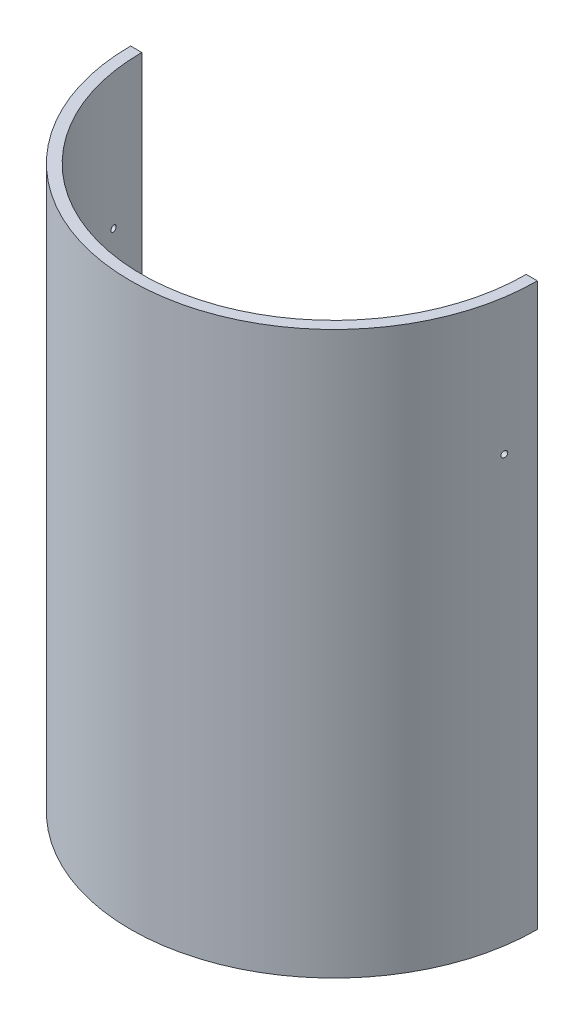
from build123d import *

# Parameters (mm, degrees)
SKETCH1_R               = 94.996
SKETCH1_R_2             = 53.975
TOP_OF_HATCH_DEPTH      = 3.302
SKETCH2_R               = 94.996
SKETCH2_R_2             = 89.789
HATCH_BODY_DEPTH        = 259.08
SKETCH3_R               = 13.335
CHARGE_TUBE_HOLES_DEPTH = 263.382
SKETCH4_R               = 3.81
BOLT_HOLES_DEPTH        = 263.382
SKETCH_5_R              = 5.08
ANTENNA_HOLES_DEPTH     = 263.382
SKETCH5_R               = 3.81
SKETCH5_R_2             = 3.175
INNER_SCREW_HOLES_DEPTH = 263.382
SKETCH8_R               = 1.397
CUT_EXTRUDE1_DEPTH      = 190.992
CUT_EXTRUDE4_DEPTH      = 263.3820001


with BuildPart() as part:
    # Sketch1 → Top of Hatch (new body)
    with BuildSketch(Plane(origin=(0, 0, 0), x_dir=(1, 0, 0), z_dir=(0, 1, 0))):
        Circle(SKETCH1_R)
        Circle(SKETCH1_R_2, mode=Mode.SUBTRACT)
    extrude(amount=TOP_OF_HATCH_DEPTH)

    # Sketch2 → Hatch Body (add)
    with BuildSketch(Plane(origin=(0, 3.302, 0), x_dir=(1, 0, 0), z_dir=(0, 1, 0))):
        Circle(SKETCH2_R)
        Circle(SKETCH2_R_2, mode=Mode.SUBTRACT)
    extrude(amount=HATCH_BODY_DEPTH)

    # Sketch3 → Charge Tube Holes (cut, through all)
    with BuildSketch(Plane.XZ):
        with Locations((-76.454, 0)):
            Circle(SKETCH3_R)
        with Locations((76.454, 0)):
            Circle(SKETCH3_R)
    extrude(amount=-CHARGE_TUBE_HOLES_DEPTH, mode=Mode.SUBTRACT)

    # Sketch4 → Bolt Holes (cut, through all)
    with BuildSketch(Plane.XZ):
        with Locations((-38.1, -65.991135768)):
            Circle(SKETCH4_R)
        with Locations((-38.1, 65.991135768)):
            Circle(SKETCH4_R)
        with Locations((38.1, 65.991135768)):
            Circle(SKETCH4_R)
        with Locations((38.1, -65.991135768)):
            Circle(SKETCH4_R)
    extrude(amount=-BOLT_HOLES_DEPTH, mode=Mode.SUBTRACT)

    # Sketch 5 → Antenna Holes (cut, through all)
    with BuildSketch(Plane.XZ):
        with Locations((-26.112352144, 57.324838678)):
            Circle(SKETCH_5_R)
        with Locations((9.193647856, 61.033450854)):
            Circle(SKETCH_5_R)
    extrude(amount=-ANTENNA_HOLES_DEPTH, mode=Mode.SUBTRACT)

    # Sketch5 → Inner Screw Holes (cut, through all)
    with BuildSketch(Plane.XZ):
        with Locations((58.42, 0)):
            Circle(SKETCH5_R)
        with Locations((-58.42, 0)):
            Circle(SKETCH5_R)
        with Locations((39.878, 41.91)):
            Circle(SKETCH5_R_2)
        with Locations((-39.878, 41.91)):
            Circle(SKETCH5_R_2)
        with Locations((39.878, -41.91)):
            Circle(SKETCH5_R_2)
        with Locations((-39.878, -41.91)):
            Circle(SKETCH5_R_2)
    extrude(amount=-INNER_SCREW_HOLES_DEPTH, mode=Mode.SUBTRACT)

    # Sketch8 → Cut-Extrude1 (cut, through all)
    with BuildSketch(Plane(origin=(94.996, 0, 0), x_dir=(0, 0, -1), z_dir=(1, 0, 0))):
        with Locations((14.351, 198.882)):
            Circle(SKETCH8_R)
        with Locations((-14.351, 198.882)):
            Circle(SKETCH8_R)
    extrude(amount=-CUT_EXTRUDE1_DEPTH, mode=Mode.SUBTRACT)

    # Sketch12 → Cut-Extrude4 (cut, through all)
    with BuildSketch(Plane.XZ):
        with BuildLine():
            Line((-94.996, 0), (94.996, 0))
            ThreePointArc((94.996, 0), (0, -94.996), (-94.996, 0))
        make_face()
    extrude(amount=-CUT_EXTRUDE4_DEPTH, mode=Mode.SUBTRACT)


solid = part.part
